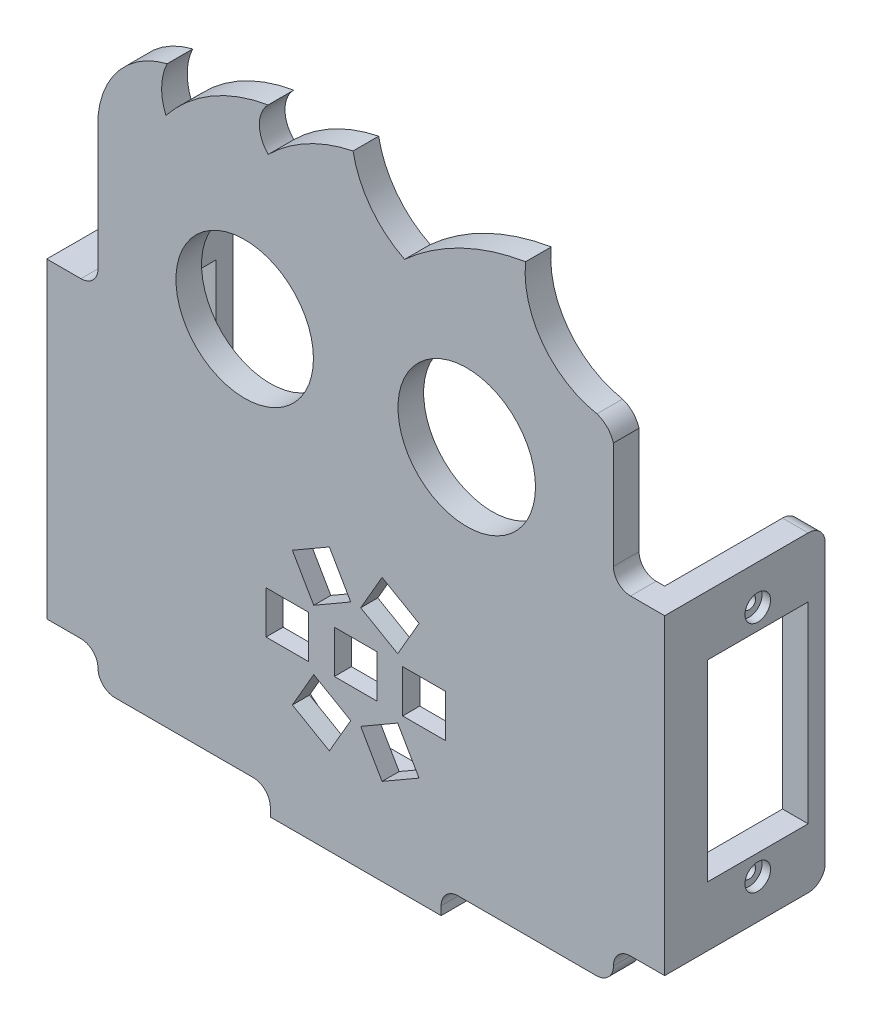
from build123d import *

# Parameters (mm, degrees)
MODEL_R                  = 8.05
MODEL_W                  = 5
MODEL_H                  = 5
SALIENTE_EXTRUIR1_DEPTH  = 3
CROQUIS3_W               = 3
CROQUIS3_H               = 36.5
SALIENTE_EXTRUIR2_DEPTH  = 15.8
CROQUIS4_R               = 0.75
CROQUIS4_W               = 11.8
CROQUIS4_H               = 22.5
CORTAR_EXTRUIR1_DEPTH    = 3
CROQUIS5_R               = 1.5
CORTAR_EXTRUIR2_DEPTH    = 1
REDONDEO1_R              = 2
REDONDEO1_OF_SIMETR_A1_R = 2
CROQUIS6_W               = 19.999999999
CROQUIS6_H               = 3
SALIENTE_EXTRUIR3_DEPTH  = 8
REDONDEO2_R              = 2
CROQUIS7_R               = 1.5
CORTAR_EXTRUIR3_DEPTH    = 3
CROQUIS8_R               = 2.25
CORTAR_EXTRUIR4_DEPTH    = 1
CROQUIS9_R               = 12
CORTAR_EXTRUIR5_DEPTH    = 1


with BuildPart() as part:
    # Model → Saliente-Extruir1 (new body)
    with BuildSketch(Plane.XY):
        with BuildLine():
            Line((24.527119253, -12.520997464), (24.527119253, -49.020997464))
            Line((24.527119253, -49.020997464), (28.527119253, -49.020997464))
            ThreePointArc((28.527119253, -49.020997464), (29.941332816, -49.606783901), (30.527119253, -51.020997464))
            ThreePointArc((30.527119253, -51.020997464), (31.112905691, -52.435211026), (32.527119253, -53.020997464))
            Line((32.527119253, -53.020997464), (48.698959582, -53.020997464))
            ThreePointArc((48.698959582, -53.020997464), (50.113173145, -53.606783901), (50.698959583, -55.020997464))
            Line((50.698959583, -55.020997464), (50.698959583, -56.020997464))
            Line((50.698959583, -56.020997464), (70.698959582, -56.020997464))
            Line((70.698959582, -56.020997464), (70.698959582, -55.020997464))
            ThreePointArc((70.698959582, -55.020997464), (71.28474602, -53.606783901), (72.698959583, -53.020997464))
            Line((72.698959583, -53.020997464), (88.870799912, -53.020997464))
            ThreePointArc((88.870799912, -53.020997464), (90.285013474, -52.435211026), (90.870799912, -51.020997464))
            ThreePointArc((90.870799912, -51.020997464), (91.456586349, -49.606783901), (92.870799912, -49.020997464))
            Line((92.870799912, -49.020997464), (96.870799912, -49.020997464))
            Line((96.870799912, -49.020997464), (96.870799912, -12.520997464))
            Line((96.870799912, -12.520997464), (92.870799912, -12.520997464))
            ThreePointArc((92.870799912, -12.520997464), (91.456586349, -11.935211026), (90.870799912, -10.520997464))
            Line((90.870799912, -10.520997464), (90.870799912, 1.98809425))
            ThreePointArc((90.870799912, 1.98809425), (90.150187884, 3.221976478), (88.940527152, 3.982547289))
            ThreePointArc((88.940527152, 3.982547289), (82.560153742, 7.972895656), (80.592387516, 15.236499516))
            ThreePointArc((80.592387516, 15.236499516), (73.016137183, 12.831206377), (66.424253692, 8.389126209))
            ThreePointArc((66.424253692, 8.389126209), (62.464845981, 11.66270114), (60.387431279, 16.361376528))
            ThreePointArc((60.387431279, 16.361376528), (55.039384462, 14.426569266), (50.461877073, 11.051438157))
            ThreePointArc((50.461877073, 11.051438157), (49.41482724, 13.546636971), (50.438823204, 16.051385009))
            ThreePointArc((50.438823204, 16.051385009), (43.800023098, 13.634815248), (38.471226177, 8.99613013))
            ThreePointArc((38.471226177, 8.99613013), (37.976525569, 11.673196605), (38.618250464, 14.318872844))
            ThreePointArc((38.618250464, 14.318872844), (33.077419178, 10.94136051), (30.527119253, 4.974420659))
            Line((30.527119253, 4.974420659), (30.527119253, -10.520997464))
            ThreePointArc((30.527119253, -10.520997464), (29.941332816, -11.935211026), (28.527119253, -12.520997464))
            Line((28.527119253, -12.520997464), (24.527119253, -12.520997464))
        make_face()
        with Locations((73.698959582, -7.020997464)):
            Circle(MODEL_R, mode=Mode.SUBTRACT)
        with Locations((47.698959583, -7.020997464)):
            Circle(MODEL_R, mode=Mode.SUBTRACT)
        with Locations((60.698959582, -35.520997464)):
            Rectangle(MODEL_W, MODEL_H, mode=Mode.SUBTRACT)
        with Locations((52.698959582, -35.520997464)):
            Rectangle(MODEL_W, MODEL_H, mode=Mode.SUBTRACT)
        Polygon((57.614023092, -25.177730724), (53.283896073, -27.677730724), (55.783896073, -32.007857743), (60.114023092, -29.507857743), align=None, mode=Mode.SUBTRACT)
        Polygon((68.114023092, -27.677730724), (63.783896073, -25.177730724), (61.283896073, -29.507857743), (65.614023092, -32.007857743), align=None, mode=Mode.SUBTRACT)
        with Locations((68.698959582, -35.520997464)):
            Rectangle(MODEL_W, MODEL_H, mode=Mode.SUBTRACT)
        Polygon((63.783896073, -45.864264204), (68.114023092, -43.364264204), (65.614023092, -39.034137185), (61.283896073, -41.534137185), align=None, mode=Mode.SUBTRACT)
        Polygon((53.283896073, -43.364264203), (57.614023092, -45.864264203), (60.114023092, -41.534137185), (55.783896073, -39.034137185), align=None, mode=Mode.SUBTRACT)
    extrude(amount=SALIENTE_EXTRUIR1_DEPTH)

    # Croquis3 → Saliente-Extruir2 (add)
    with BuildSketch(Plane(origin=(0, 0, 0), x_dir=(-1, 0, 0), z_dir=(0, 0, -1))):
        with Locations((-95.370799912, -30.770997464)):
            Rectangle(CROQUIS3_W, CROQUIS3_H)
    saliente_extruir2 = extrude(amount=SALIENTE_EXTRUIR2_DEPTH)

    # Croquis4 → Cortar-Extruir1 (cut)
    with BuildSketch(Plane(origin=(96.870799912, 0, 0), x_dir=(0, 0, -1), z_dir=(1, 0, 0))):
        with Locations((7.9, -44.420997464)):
            Circle(CROQUIS4_R)
        with Locations((7.9, -17.120997464)):
            Circle(CROQUIS4_R)
        with Locations((7.9, -30.770997464)):
            Rectangle(CROQUIS4_W, CROQUIS4_H)
    cortar_extruir1 = extrude(amount=-CORTAR_EXTRUIR1_DEPTH, mode=Mode.SUBTRACT)

    # Croquis5 → Cortar-Extruir2 (cut)
    with BuildSketch(Plane(origin=(96.870799912, 0, 0), x_dir=(0, 0, -1), z_dir=(1, 0, 0))):
        with Locations((7.9, -17.120997464)):
            Circle(CROQUIS5_R)
        with Locations((7.9, -44.420997464)):
            Circle(CROQUIS5_R)
    cortar_extruir2 = extrude(amount=-CORTAR_EXTRUIR2_DEPTH, mode=Mode.SUBTRACT)

    # Redondeo1
    redondeo1_edges = [part.edges().sort_by_distance(p)[0] for p in [
        (95.370799912, -49.020997464, -15.8),
        (95.370799912, -12.520997464, -15.8),
    ]]
    fillet(redondeo1_edges, radius=REDONDEO1_R)

    # Simetría1: Saliente-Extruir2, Cortar-Extruir1, Cortar-Extruir2 across plane
    add(saliente_extruir2.mirror(Plane(origin=(60.700799912, 0, 0), x_dir=(0, 0, 1), z_dir=(1, 0, 0))))
    add(cortar_extruir1.mirror(Plane(origin=(60.700799912, 0, 0), x_dir=(0, 0, 1), z_dir=(1, 0, 0))), mode=Mode.SUBTRACT)
    add(cortar_extruir2.mirror(Plane(origin=(60.700799912, 0, 0), x_dir=(0, 0, 1), z_dir=(1, 0, 0))), mode=Mode.SUBTRACT)

    # Redondeo1 of Simetría1
    redondeo1_of_simetr_a1_edges = [part.edges().sort_by_distance(p)[0] for p in [
        (26.030799912, -49.020997464, -15.8),
        (26.030799912, -12.520997464, -15.8),
    ]]
    fillet(redondeo1_of_simetr_a1_edges, radius=REDONDEO1_OF_SIMETR_A1_R)

    # Croquis6 → Saliente-Extruir3 (add)
    with BuildSketch(Plane(origin=(0, 0, 0), x_dir=(-1, 0, 0), z_dir=(0, 0, -1))):
        with Locations((-60.698959583, -54.520997464)):
            Rectangle(CROQUIS6_W, CROQUIS6_H)
    extrude(amount=SALIENTE_EXTRUIR3_DEPTH)

    # Redondeo2
    redondeo2_edges = [part.edges().sort_by_distance(p)[0] for p in [
        (50.698959583, -54.520997464, -8),
        (70.698959582, -54.520997464, -8),
    ]]
    fillet(redondeo2_edges, radius=REDONDEO2_R)

    # Croquis7 → Cortar-Extruir3 (cut)
    with BuildSketch(Plane(origin=(0, -53.020997464, 0), x_dir=(1, 0, 0), z_dir=(0, 1, 0))):
        with Locations((66.698959583, 3.5)):
            Circle(CROQUIS7_R)
        with Locations((54.698959582, 3.5)):
            Circle(CROQUIS7_R)
    extrude(amount=-CORTAR_EXTRUIR3_DEPTH, mode=Mode.SUBTRACT)

    # Croquis8 → Cortar-Extruir4 (cut)
    with BuildSketch(Plane(origin=(0, -53.020997464, 0), x_dir=(1, 0, 0), z_dir=(0, 1, 0))):
        with Locations((66.698959583, 3.5)):
            Circle(CROQUIS8_R)
        with Locations((54.698959582, 3.5)):
            Circle(CROQUIS8_R)
    extrude(amount=-CORTAR_EXTRUIR4_DEPTH, mode=Mode.SUBTRACT)

    # Croquis9 → Cortar-Extruir5 (cut)
    with BuildSketch(Plane(origin=(0, 0, 0), x_dir=(-1, 0, 0), z_dir=(0, 0, -1))):
        with Locations((-60.698959582, -35.520997464)):
            Circle(CROQUIS9_R)
    extrude(amount=-CORTAR_EXTRUIR5_DEPTH, mode=Mode.SUBTRACT)


solid = part.part
